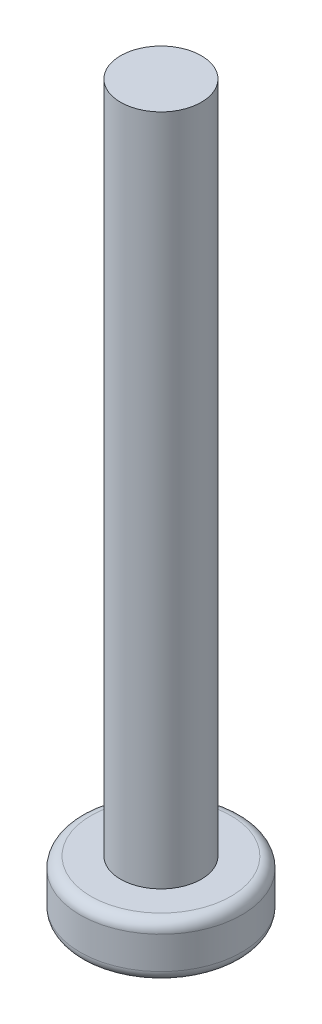
from build123d import *

# Parameters (mm, degrees)
SKETCH1_R           = 3
BOSS_EXTRUDE1_DEPTH = 2
SKETCH2_R           = 1.5
BOSS_EXTRUDE2_DEPTH = 25
SKETCH3_W           = 0.9
SKETCH3_H           = 0.9
SKETCH3_W_2         = 1.05
SKETCH3_H_2         = 1.05
CUT_EXTRUDE1_DEPTH  = 1.9
FILLET1_R           = 0.4


with BuildPart() as part:
    # Sketch1 → Boss-Extrude1 (new body)
    with BuildSketch(Plane(origin=(0, 0, 0), x_dir=(1, 0, 0), z_dir=(0, 1, 0))):
        Circle(SKETCH1_R)
    extrude(amount=BOSS_EXTRUDE1_DEPTH)

    # Sketch2 → Boss-Extrude2 (add)
    with BuildSketch(Plane(origin=(0, 2, 0), x_dir=(1, 0, 0), z_dir=(0, 1, 0))):
        Circle(SKETCH2_R)
    extrude(amount=BOSS_EXTRUDE2_DEPTH)

    # Sketch3 → Cut-Extrude1 (cut)
    with BuildSketch(Plane(origin=(0, 0, 0), x_dir=(-1, 0, 0), z_dir=(0, -1, 0))):
        Rectangle(SKETCH3_W, SKETCH3_H)
        with Locations((0.975, 0)):
            Rectangle(SKETCH3_W_2, SKETCH3_H)
        with Locations((0, -0.975)):
            Rectangle(SKETCH3_W, SKETCH3_H_2)
        with Locations((-0.975, 0)):
            Rectangle(SKETCH3_W_2, SKETCH3_H)
        with Locations((0, 0.975)):
            Rectangle(SKETCH3_W, SKETCH3_H_2)
    extrude(amount=-CUT_EXTRUDE1_DEPTH, mode=Mode.SUBTRACT)

    # Fillet1
    fillet1_edges = [part.edges().sort_by_distance(p)[0] for p in [
        (-3, 0, 0),
        (-3, 2, 0),
    ]]
    fillet(fillet1_edges, radius=FILLET1_R)


solid = part.part
